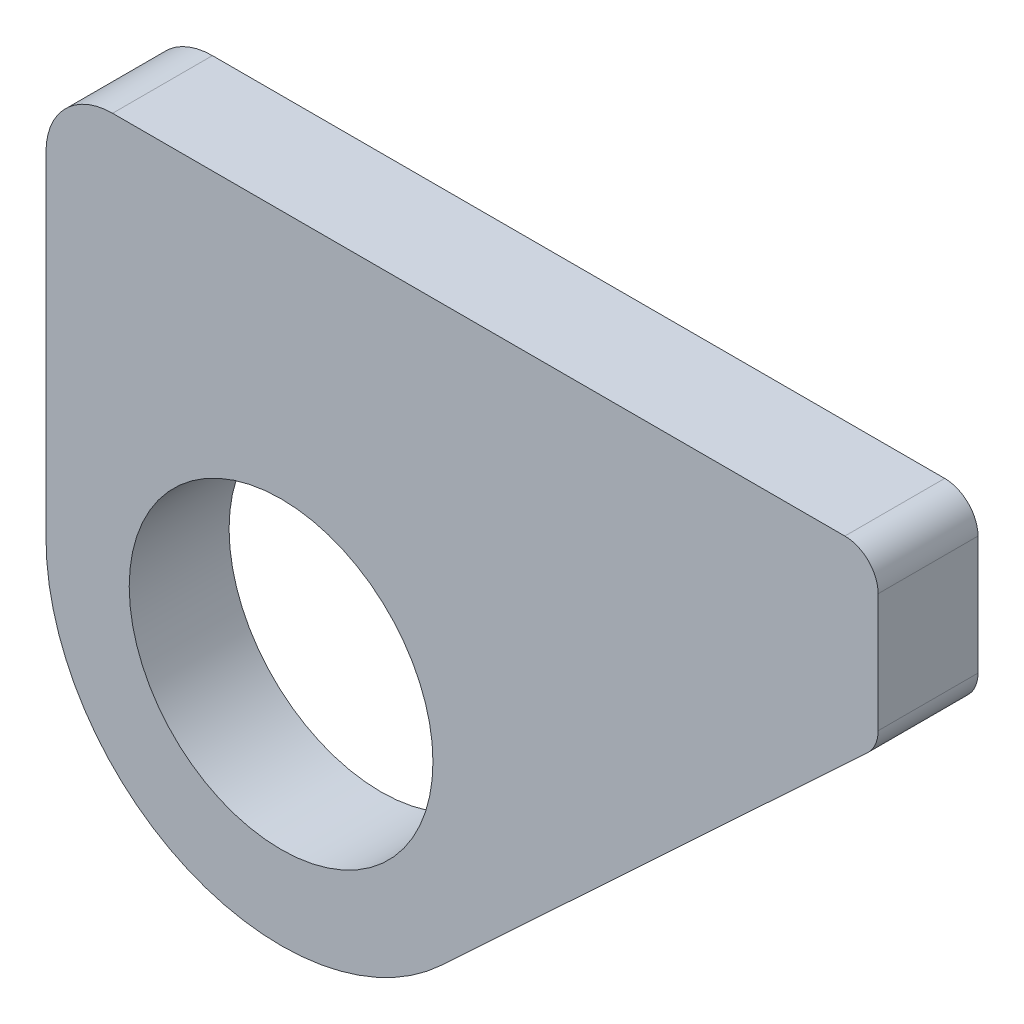
from build123d import *

# Parameters (mm, degrees)
SKETCH1_R           = 7.0625
SKETCH1_R_2         = 4.5625
BOSS_EXTRUDE1_DEPTH = 3
FILLET1_R           = 2
FILLET2_R           = 1


with BuildPart() as part:
    # Sketch1 → Boss-Extrude1 (new body)
    with BuildSketch(Plane.XY):
        with Locations((115.113664311, 46.337958859)):
            Circle(SKETCH1_R)
        with Locations((115.113664311, 46.337958859)):
            Circle(SKETCH1_R_2, mode=Mode.SUBTRACT)
        with BuildLine():
            ThreePointArc((108.051164311, 46.337958859), (110.119722669, 51.331900502), (115.113664311, 53.400458859))
            Line((115.113664311, 53.400458859), (108.051164311, 53.400458859))
            Line((108.051164311, 53.400458859), (108.051164311, 46.337958859))
        make_face()
        with BuildLine():
            Line((108.051164311, 53.400458859), (115.113664311, 53.400458859))
            ThreePointArc((115.113664311, 53.400458859), (120.107605953, 51.331900502), (122.176164311, 46.337958859))
            ThreePointArc((122.176164311, 46.337958859), (121.589956666, 43.520771685), (119.928647546, 41.171253652))
            Line((119.928647546, 41.171253652), (133.051164311, 53.400458859))
            Line((133.051164311, 53.400458859), (133.051164311, 58.400458859))
            Line((133.051164311, 58.400458859), (108.051164311, 58.400458859))
            Line((108.051164311, 58.400458859), (108.051164311, 53.400458859))
        make_face()
    extrude(amount=BOSS_EXTRUDE1_DEPTH)

    # Fillet1
    fillet1_edges = [part.edges().sort_by_distance(p)[0] for p in [
        (108.051164311, 58.400458859, 1.5),
    ]]
    fillet(fillet1_edges, radius=FILLET1_R)

    # Fillet2
    fillet2_edges = [part.edges().sort_by_distance(p)[0] for p in [
        (133.051164311, 58.400458859, 1.5),
        (133.051164311, 53.400458859, 1.5),
    ]]
    fillet(fillet2_edges, radius=FILLET2_R)


solid = part.part
